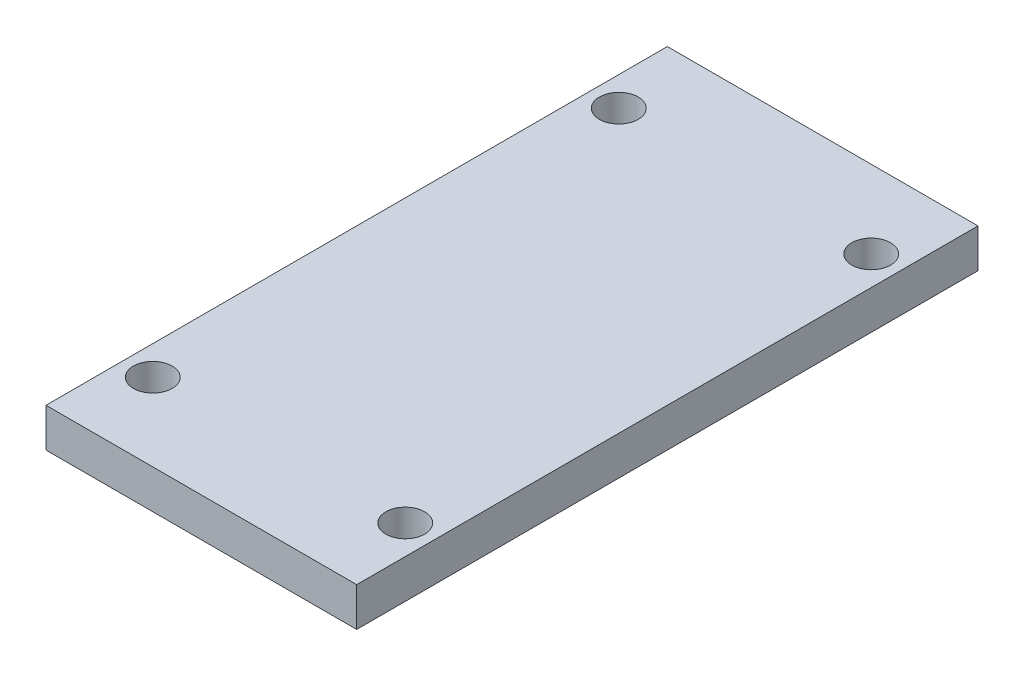
from build123d import *

# Parameters (mm, degrees)
SKETCH2_W           = 80
SKETCH2_H           = 160
BOSS_EXTRUDE1_DEPTH = 10
SKETCH3_R           = 5
CUT_EXTRUDE1_DEPTH  = 10


with BuildPart() as part:
    # Sketch2 → Boss-Extrude1 (new body)
    with BuildSketch(Plane(origin=(0, 0, 0), x_dir=(1, 0, 0), z_dir=(0, 1, 0))):
        with Locations((40, -80)):
            Rectangle(SKETCH2_W, SKETCH2_H)
    extrude(amount=BOSS_EXTRUDE1_DEPTH)

    # Sketch3 → Cut-Extrude1 (cut)
    with BuildSketch(Plane(origin=(0, 10, 0), x_dir=(1, 0, 0), z_dir=(0, 1, 0))):
        with Locations((7.5, -140)):
            Circle(SKETCH3_R)
        with Locations((72.5, -140)):
            Circle(SKETCH3_R)
        with Locations((72.5, -20)):
            Circle(SKETCH3_R)
        with Locations((7.5, -20)):
            Circle(SKETCH3_R)
    extrude(amount=-CUT_EXTRUDE1_DEPTH, mode=Mode.SUBTRACT)


solid = part.part
